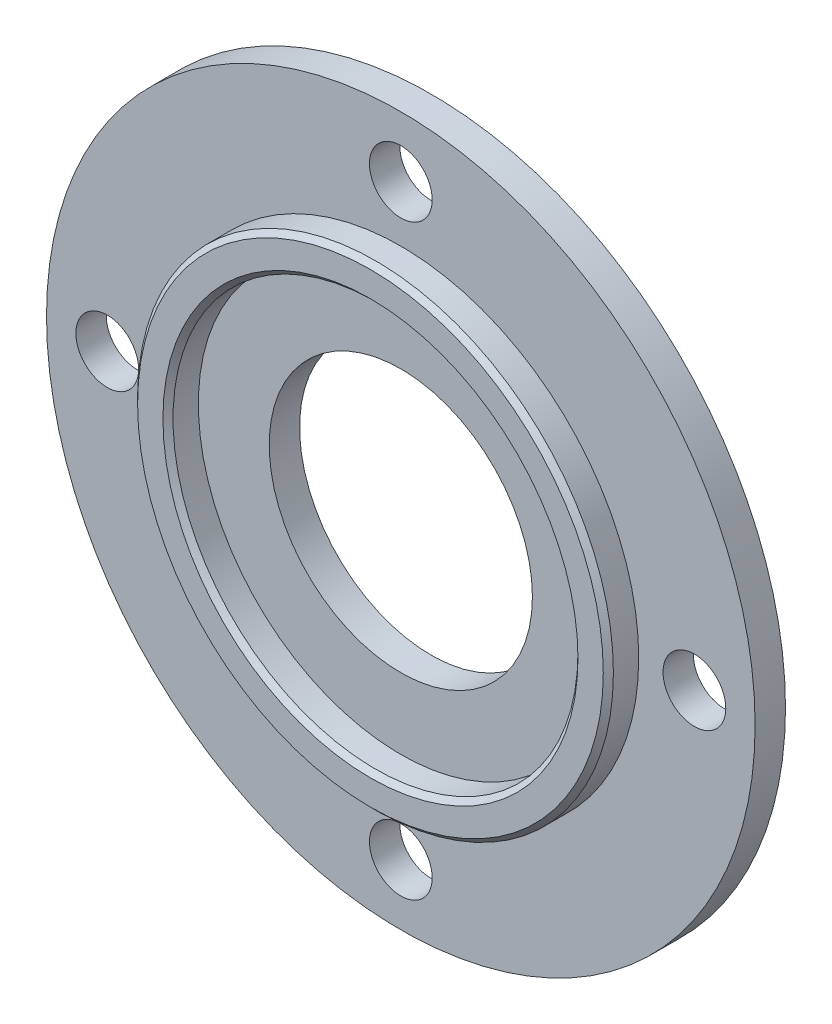
from build123d import *

# Parameters (mm, degrees)
SKETCH1_R           = 35
BOSS_EXTRUDE1_DEPTH = 3
SKETCH2_R           = 13
SKETCH2_R_2         = 3.1
CUT_EXTRUDE1_DEPTH  = 3
SKETCH3_R           = 23.5
SKETCH3_R_2         = 20
BOSS_EXTRUDE2_DEPTH = 3
CHAMFER1_SIZE       = 0.5
CHAMFER2_SIZE       = 0.5


with BuildPart() as part:
    # Sketch1 → Boss-Extrude1 (new body)
    with BuildSketch(Plane.XY):
        Circle(SKETCH1_R)
    extrude(amount=BOSS_EXTRUDE1_DEPTH)

    # Sketch2 → Cut-Extrude1 (cut)
    with BuildSketch(Plane.XY.offset(3)):
        Circle(SKETCH2_R)
        with Locations((0, 29)):
            Circle(SKETCH2_R_2)
        with Locations((29, 0)):
            Circle(SKETCH2_R_2)
        with Locations((0, -29)):
            Circle(SKETCH2_R_2)
        with Locations((-29, 0)):
            Circle(SKETCH2_R_2)
    extrude(amount=-CUT_EXTRUDE1_DEPTH, mode=Mode.SUBTRACT)

    # Sketch3 → Boss-Extrude2 (add)
    with BuildSketch(Plane.XY.offset(3)):
        Circle(SKETCH3_R)
        Circle(SKETCH3_R_2, mode=Mode.SUBTRACT)
    extrude(amount=BOSS_EXTRUDE2_DEPTH)

    # Chamfer1
    chamfer1_edges = [part.edges().sort_by_distance(p)[0] for p in [
        (-23.5, 0, 6),
    ]]
    chamfer(chamfer1_edges, length=CHAMFER1_SIZE)

    # Chamfer2
    chamfer2_edges = [part.edges().sort_by_distance(p)[0] for p in [
        (-20, 0, 6),
    ]]
    chamfer(chamfer2_edges, length=CHAMFER2_SIZE)


solid = part.part
